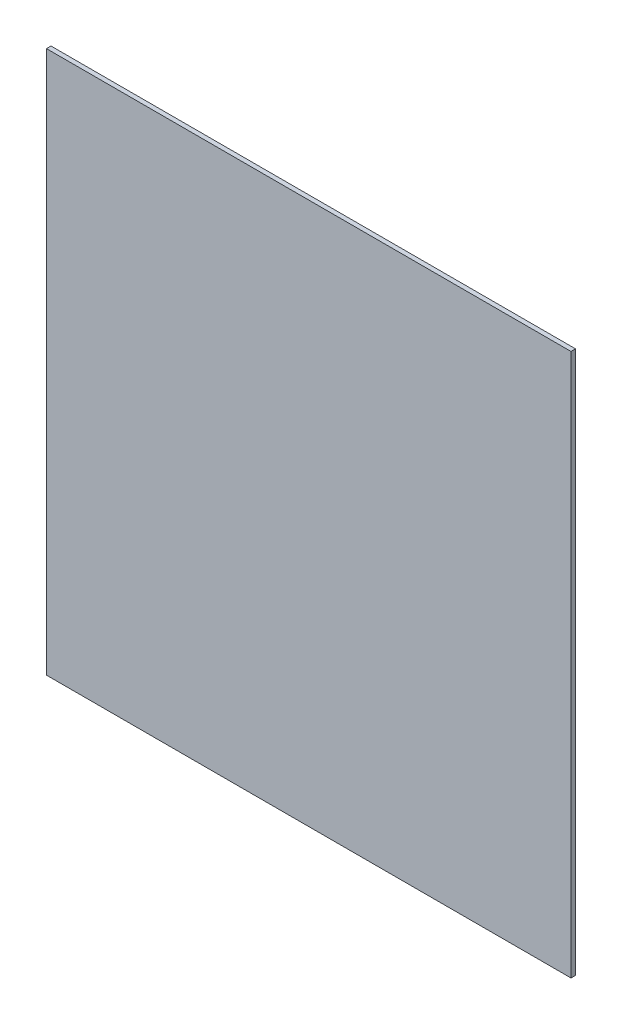
from build123d import *

# Parameters (mm, degrees)
SKETCH1_W           = 580
SKETCH1_H           = 600
BOSS_EXTRUDE1_DEPTH = 5


with BuildPart() as part:
    # Sketch1 → Boss-Extrude1 (new body)
    with BuildSketch(Plane.XY):
        Rectangle(SKETCH1_W, SKETCH1_H)
    extrude(amount=BOSS_EXTRUDE1_DEPTH)


solid = part.part
